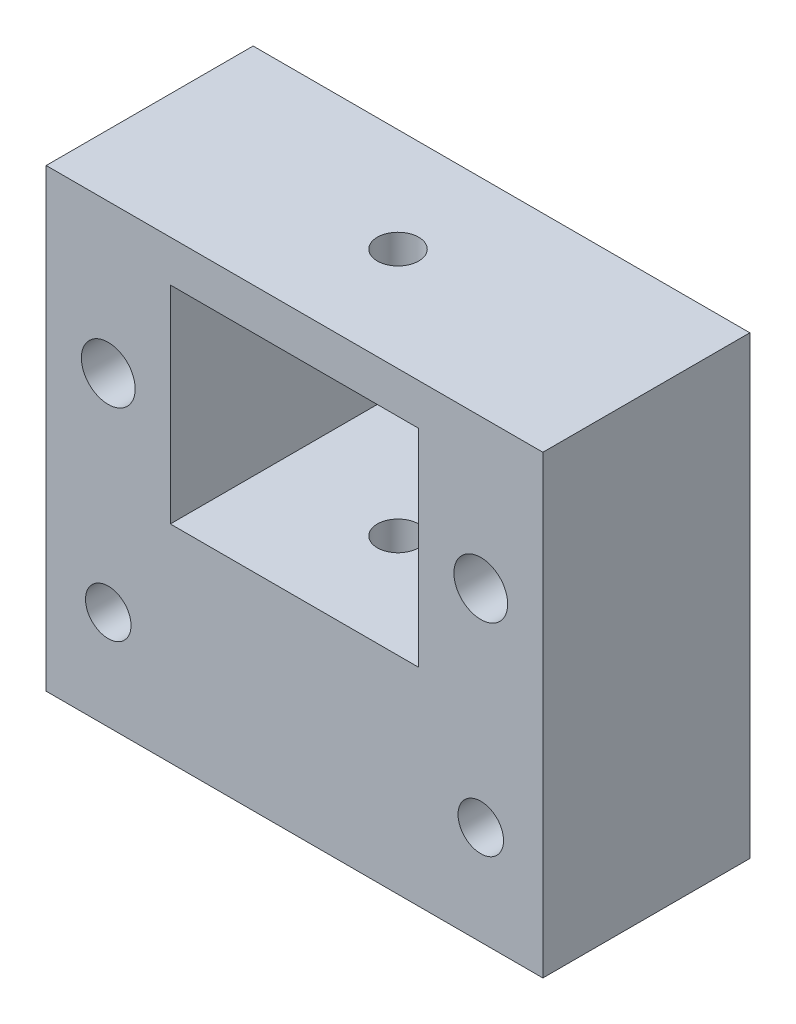
from build123d import *

# Parameters (mm, degrees)
SKETCH2_W           = 60
SKETCH2_H           = 25
BOSS_EXTRUDE1_DEPTH = 55
CUT_EXTRUDE1_REACH  = 27
SKETCH3_W           = 30
SKETCH3_H           = 25
SKETCH4_R           = 2.5
CUT_EXTRUDE2_DEPTH  = 56
SKETCH5_R           = 3.25
SKETCH5_R_2         = 2.75
CUT_EXTRUDE3_DEPTH  = 26
SKETCH9_R           = 4.45
CUT_EXTRUDE7_DEPTH  = 11.5


with BuildPart() as part:
    # Sketch2 → Boss-Extrude1 (new body)
    with BuildSketch(Plane(origin=(0, 0, 0), x_dir=(1, 0, 0), z_dir=(0, 1, 0))):
        with Locations((30, 12.5)):
            Rectangle(SKETCH2_W, SKETCH2_H)
    extrude(amount=BOSS_EXTRUDE1_DEPTH)

    # Sketch3 → Cut-Extrude1 (cut, up to next)
    with BuildSketch(Plane.XY, mode=Mode.PRIVATE) as cut_extrude1_sk1:
        with Locations((30, 37.5)):
            Rectangle(SKETCH3_W, SKETCH3_H)
    cut_extrude1_tool1 = extrude(cut_extrude1_sk1.sketch, amount=-CUT_EXTRUDE1_REACH, mode=Mode.PRIVATE) & part.part
    add(cut_extrude1_tool1.solids().sort_by_distance((30, 37.5, 0))[0], mode=Mode.SUBTRACT)

    # Sketch4 → Cut-Extrude2 (cut, through all)
    with BuildSketch(Plane(origin=(0, 55, 0), x_dir=(1, 0, 0), z_dir=(0, 1, 0))):
        with Locations((30, 12.5)):
            Circle(SKETCH4_R)
    extrude(amount=-CUT_EXTRUDE2_DEPTH, mode=Mode.SUBTRACT)

    # Sketch5 → Cut-Extrude3 (cut, through all)
    with BuildSketch(Plane.XY):
        with Locations((7.5, 37)):
            Circle(SKETCH5_R)
        with Locations((7.5, 12)):
            Circle(SKETCH5_R_2)
        with Locations((52.5, 12)):
            Circle(SKETCH5_R_2)
        with Locations((52.5, 37)):
            Circle(SKETCH5_R)
    extrude(amount=-CUT_EXTRUDE3_DEPTH, mode=Mode.SUBTRACT)

    # Sketch9 → Cut-Extrude7 (cut)
    with BuildSketch(Plane(origin=(0, 0, -25), x_dir=(-1, 0, 0), z_dir=(0, 0, -1))):
        with Locations((-52.5, 37)):
            Circle(SKETCH9_R)
        with Locations((-7.5, 37)):
            Circle(SKETCH9_R)
    extrude(amount=-CUT_EXTRUDE7_DEPTH, mode=Mode.SUBTRACT)


solid = part.part
